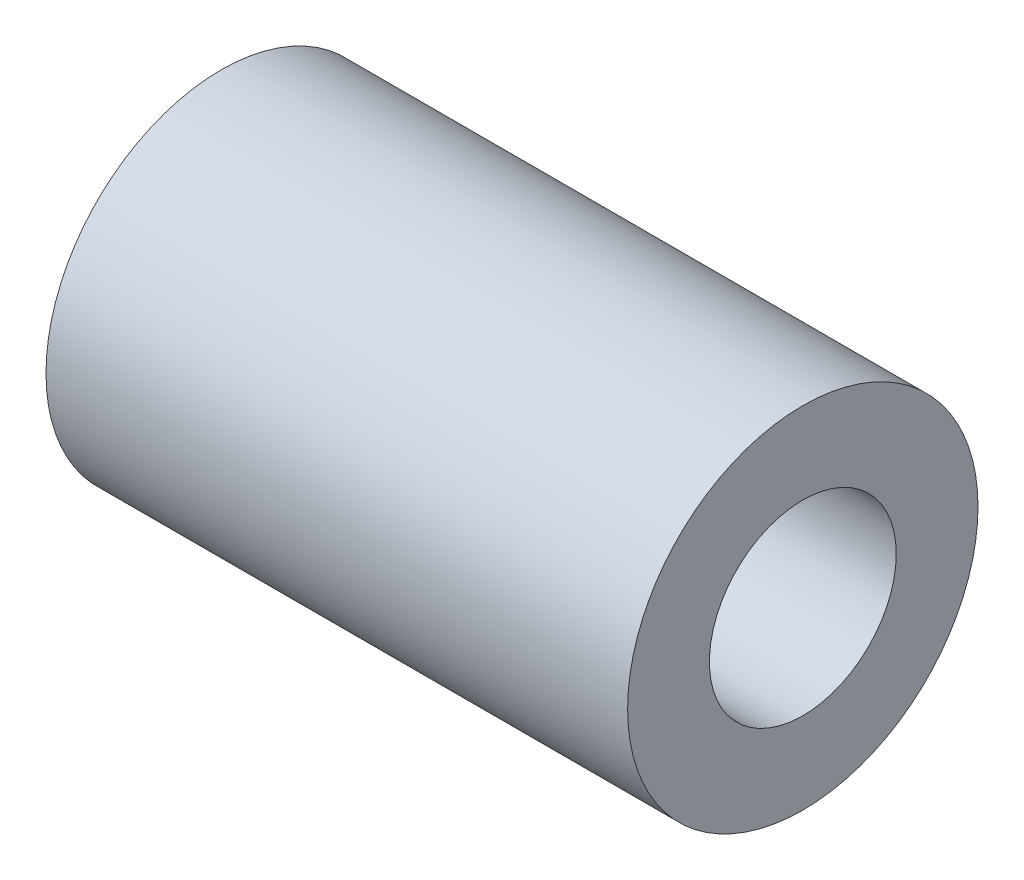
from build123d import *

# Parameters (mm, degrees)
CROQUIS1_R              = 7.5
CROQUIS1_R_2            = 4
SALIENTE_EXTRUIR1_DEPTH = 24.9


with BuildPart() as part:
    # Croquis1 → Saliente-Extruir1 (new body)
    with BuildSketch(Plane(origin=(0, 0, 0), x_dir=(0, 0, -1), z_dir=(1, 0, 0))):
        Circle(CROQUIS1_R)
        Circle(CROQUIS1_R_2, mode=Mode.SUBTRACT)
    extrude(amount=SALIENTE_EXTRUIR1_DEPTH)


solid = part.part
